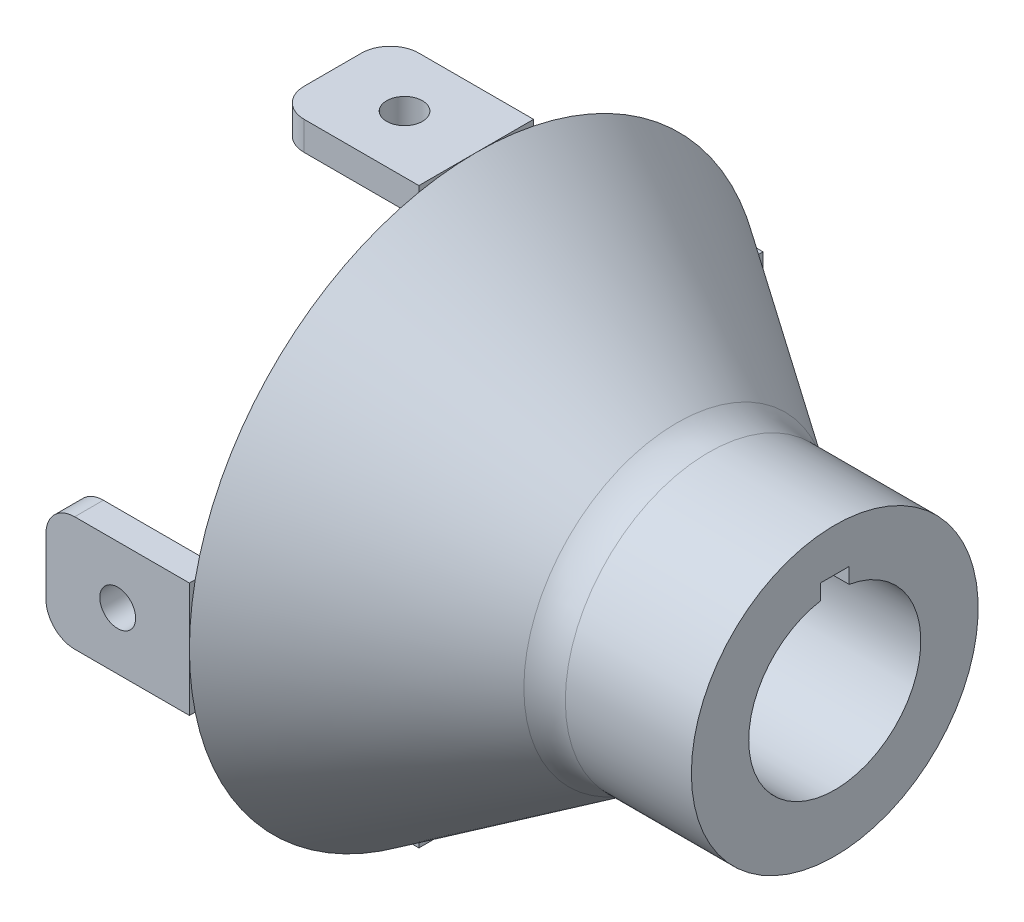
from build123d import *

# Parameters (mm, degrees)
SKETCH1_R           = 1.25
BOSS_EXTRUDE1_DEPTH = 2
CIRPATTERN1_COUNT   = 4
FILLET1_R           = 4
CUT_EXTRUDE1_DEPTH  = 8


with BuildPart() as part:
    # Sketch1 → Boss-Extrude1 (new body)
    with BuildSketch(Plane(origin=(0, 0, 0), x_dir=(1, 0, 0), z_dir=(0, 1, 0))):
        with BuildLine():
            Line((0, 4), (0, -4))
            Line((0, -4), (-8, -4))
            ThreePointArc((-8, -4), (-9.414213562, -3.414213562), (-10, -2))
            Line((-10, -2), (-10, 2))
            ThreePointArc((-10, 2), (-9.414213562, 3.414213562), (-8, 4))
            Line((-8, 4), (0, 4))
        make_face()
        with Locations((-5, 0)):
            Circle(SKETCH1_R, mode=Mode.SUBTRACT)
    boss_extrude1 = extrude(amount=BOSS_EXTRUDE1_DEPTH)

    # Sketch2 → Revolve1 (revolve)
    with BuildSketch(Plane.XY):
        Polygon((0, 2), (0, -2), (15, -12), (25, -12), (25, -8), (15, -8), align=None)
    revolve(axis=Axis((-9.784018472, -18, 0), (1, 0, 0)))

    # CirPattern1: Boss-Extrude1 ×4 about axis
    cirpattern1_axis = Axis((0, -18, 0), (1, 0, 0))
    for i in range(1, CIRPATTERN1_COUNT):
        add(boss_extrude1.rotate(cirpattern1_axis, i * 360 / CIRPATTERN1_COUNT))

    # Fillet1
    fillet1_edges = [part.edges().sort_by_distance(p)[0] for p in [
        (15, -28, 0),
    ]]
    fillet(fillet1_edges, radius=FILLET1_R)

    # Sketch3 → Cut-Extrude1 (cut)
    with BuildSketch(Plane(origin=(25, 0, 0), x_dir=(0, 0, -1), z_dir=(1, 0, 0))):
        Polygon((1, -12), (1, -11), (-1, -11), (-1, -12), (-1, -12.906953831), (1, -12.906953831), align=None)
    extrude(amount=-CUT_EXTRUDE1_DEPTH, mode=Mode.SUBTRACT)


solid = part.part
